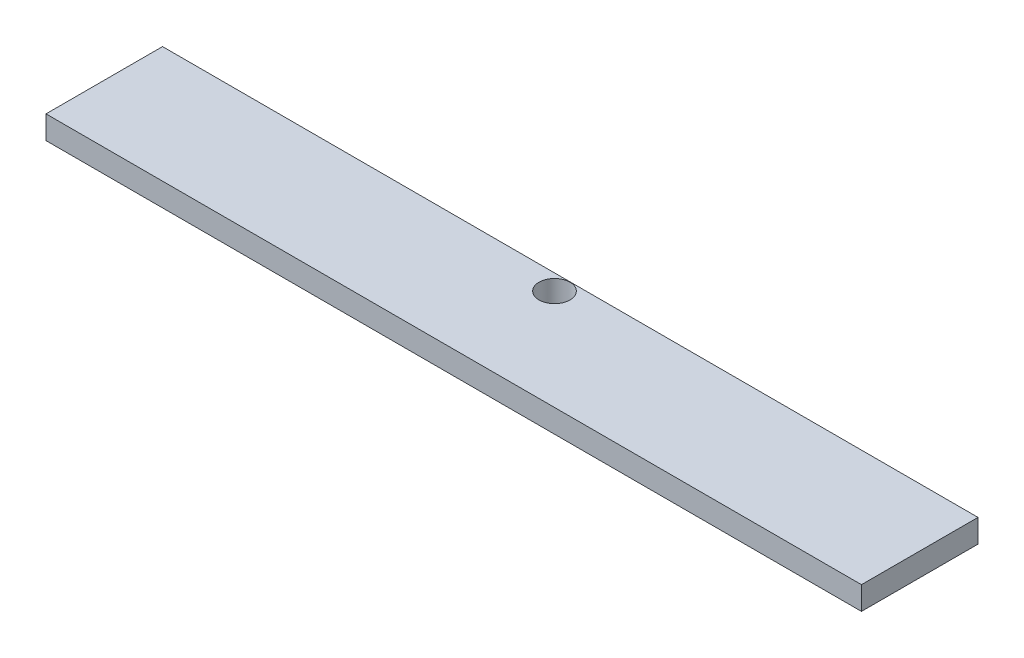
from build123d import *

# Parameters (mm, degrees)
SKETCH1_W           = 669.925
SKETCH1_H           = 95.73895
BOSS_EXTRUDE1_DEPTH = 19.05
SKETCH2_R           = 12.7
CUT_EXTRUDE4_DEPTH  = 20.05


with BuildPart() as part:
    # Sketch1 → Boss-Extrude1 (new body)
    with BuildSketch(Plane(origin=(0, 0, 0), x_dir=(1, 0, 0), z_dir=(0, 1, 0))):
        with Locations((334.9625, 47.869475)):
            Rectangle(SKETCH1_W, SKETCH1_H)
    extrude(amount=BOSS_EXTRUDE1_DEPTH)

    # Sketch2 → Cut-Extrude4 (cut, through all)
    with BuildSketch(Plane.XZ):
        with Locations((334.9625, -82.78495)):
            Circle(SKETCH2_R)
    extrude(amount=-CUT_EXTRUDE4_DEPTH, mode=Mode.SUBTRACT)


solid = part.part
